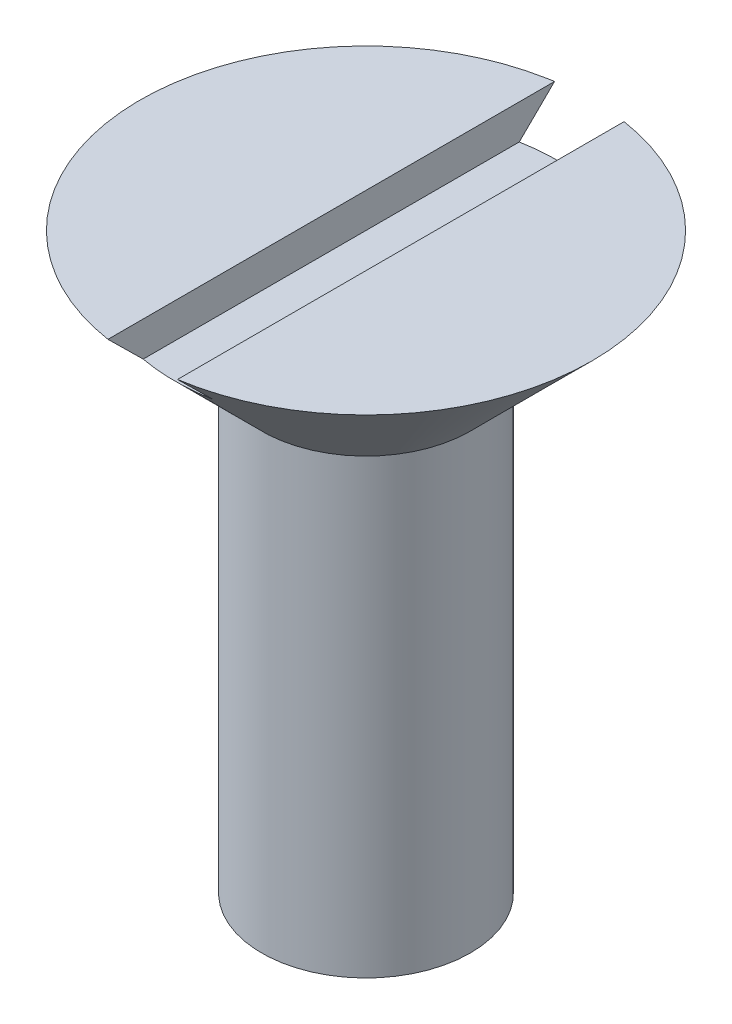
from build123d import *

# Parameters (mm, degrees)
SKETCH3_W          = 2
SKETCH3_H          = 15
CUT_EXTRUDE1_DEPTH = 1


with BuildPart() as part:
    # Sketch2 → Revolve1 (revolve)
    with BuildSketch(Plane.XY):
        Polygon((0, 0), (0, 18.232050808), (6.5, 18.232050808), (3, 14.732050808), (3, 1.732050808), align=None)
    revolve(axis=Axis((0, 0, 0), (0, 1, 0)))

    # Sketch3 → Cut-Extrude1 (cut)
    with BuildSketch(Plane(origin=(0, 18.232050808, 0), x_dir=(1, 0, 0), z_dir=(0, 1, 0))):
        Rectangle(SKETCH3_W, SKETCH3_H)
    extrude(amount=-CUT_EXTRUDE1_DEPTH, mode=Mode.SUBTRACT)


solid = part.part
